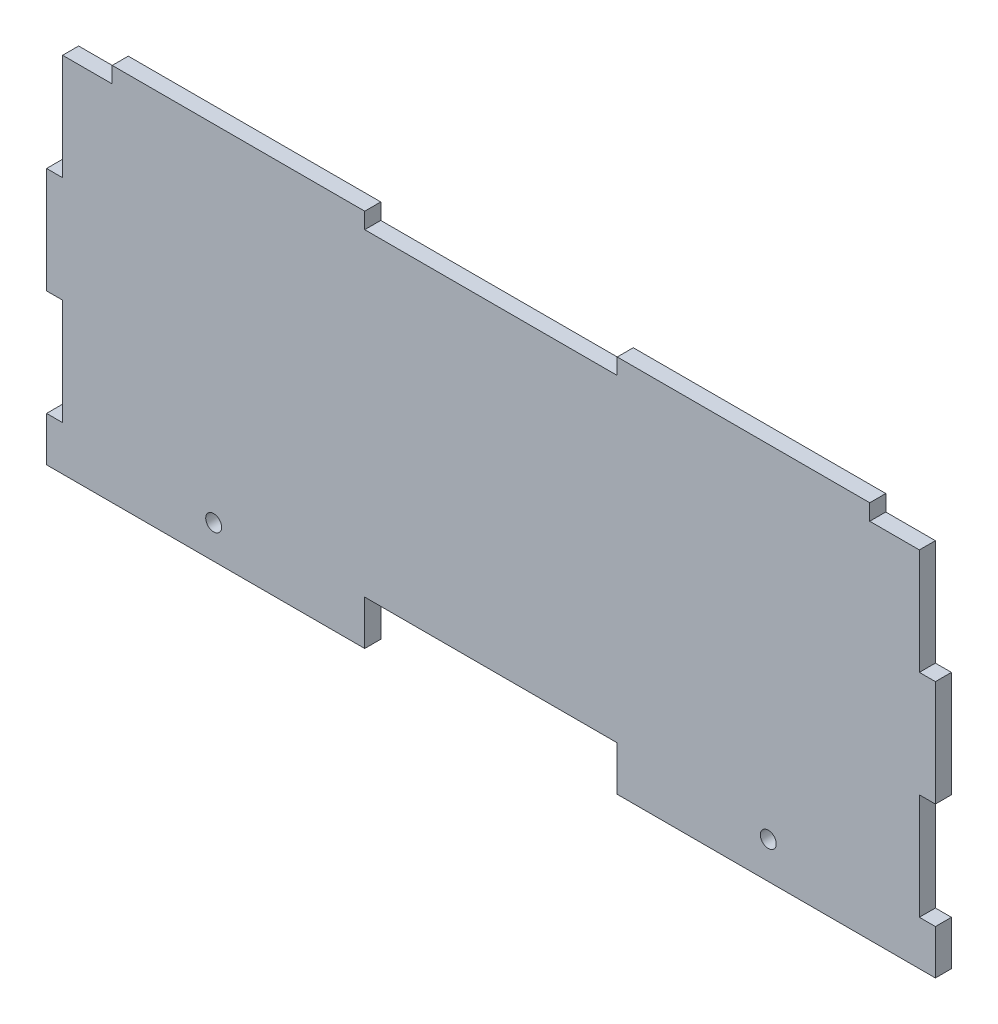
from build123d import *

# Parameters (mm, degrees)
SKETCH1_R           = 1.575
BOSS_EXTRUDE1_DEPTH = 1.5875


with BuildPart() as part:
    # Sketch1 → Boss-Extrude1 (new body, symmetric)
    with BuildSketch(Plane.XY):
        Polygon((163, 71.825), (163, 75), (113, 75), (113, 71.825), (63, 71.825), (63, 75), (13, 75), (13, 71.825), (3.175, 71.825), (3.175, 50.825), (0, 50.825), (0, 29.825), (3.175, 29.825), (3.175, 8.825), (0, 8.825), (0, 0), (63, 0), (63, 8.825), (113, 8.825), (113, 0), (176, 0), (176, 8.825), (172.825, 8.825), (172.825, 29.825), (176, 29.825), (176, 50.825), (172.825, 50.825), (172.825, 71.825), align=None)
        with Locations((33.0875, 6.61875)):
            Circle(SKETCH1_R, mode=Mode.SUBTRACT)
        with Locations((142.9125, 7.2375)):
            Circle(SKETCH1_R, mode=Mode.SUBTRACT)
    extrude(amount=BOSS_EXTRUDE1_DEPTH, both=True)


solid = part.part
